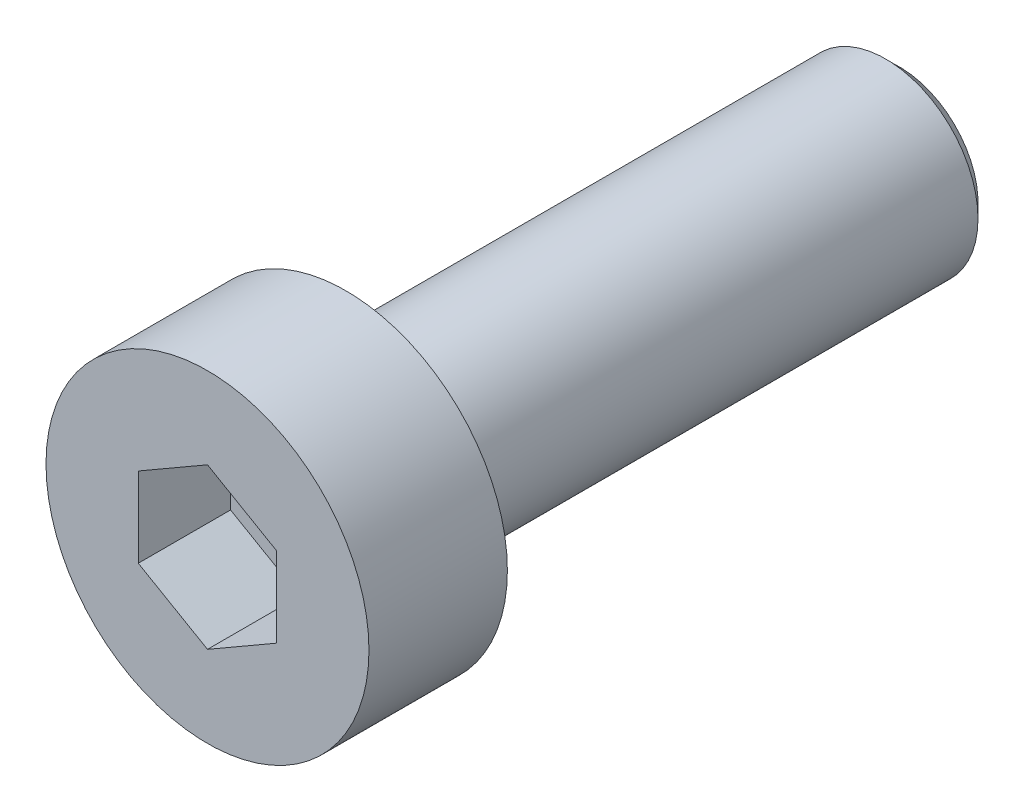
from build123d import *

# Parameters (mm, degrees)
SKETCH1_R           = 3.5
BOSS_EXTRUDE1_DEPTH = 3
SKETCH2_R           = 2
BOSS_EXTRUDE2_DEPTH = 12
CHAMFER1_SIZE       = 0.3
CUT_EXTRUDE1_DEPTH  = 2


with BuildPart() as part:
    # Sketch1 → Boss-Extrude1 (new body)
    with BuildSketch(Plane.XY):
        Circle(SKETCH1_R)
    extrude(amount=BOSS_EXTRUDE1_DEPTH)

    # Sketch2 → Boss-Extrude2 (add)
    with BuildSketch(Plane(origin=(0, 0, 0), x_dir=(-1, 0, 0), z_dir=(0, 0, -1))):
        Circle(SKETCH2_R)
    extrude(amount=BOSS_EXTRUDE2_DEPTH)

    # Chamfer1
    chamfer1_edges = [part.edges().sort_by_distance(p)[0] for p in [
        (2, 0, -12),
    ]]
    chamfer(chamfer1_edges, length=CHAMFER1_SIZE)

    # Sketch3 → Cut-Extrude1 (cut)
    with BuildSketch(Plane.XY.offset(3)):
        Polygon((0, 1.732050808), (-1.5, 0.866025404), (-1.5, -0.866025404), (0, -1.732050808), (1.5, -0.866025404), (1.5, 0.866025404), align=None)
    extrude(amount=-CUT_EXTRUDE1_DEPTH, mode=Mode.SUBTRACT)


solid = part.part
